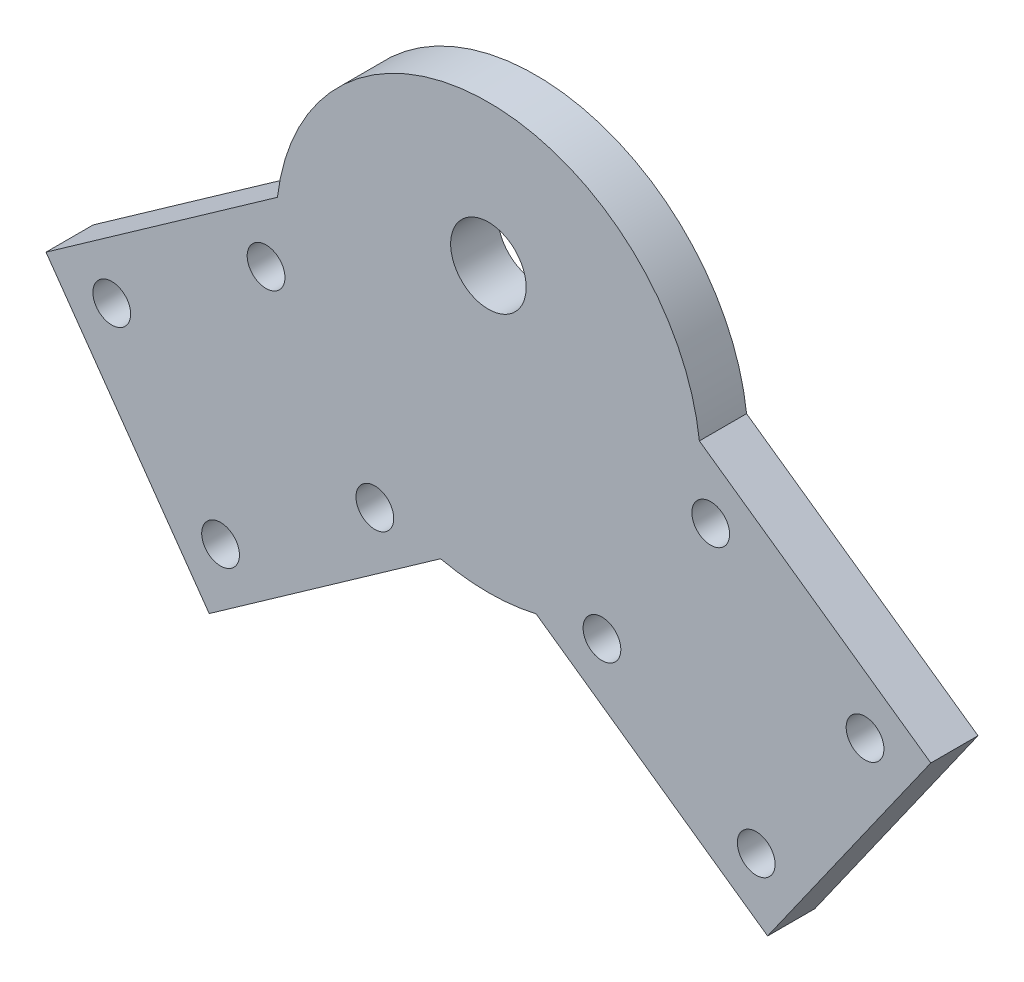
from build123d import *

# Parameters (mm, degrees)
BOSS_EXTRUDE1_DEPTH = 5
SKETCH4_R           = 2
CUT_EXTRUDE1_DEPTH  = 10
SKETCH5_R           = 4
CUT_EXTRUDE2_DEPTH  = 10


with BuildPart() as part:
    # Sketch2 → Boss-Extrude1 (new body)
    with BuildSketch(Plane.XY):
        with BuildLine():
            Line((5.061398723, -21.923326458), (29.57885851, -39.211882372))
            Line((29.57885851, -39.211882372), (46.867414424, -14.694422585))
            Line((46.867414424, -14.694422585), (22.349954637, 2.594133329))
            ThreePointArc((22.349954637, 2.594133329), (0, 22.5), (-22.349954637, 2.594133329))
            Line((-22.349954637, 2.594133329), (-46.867414424, -14.694422585))
            Line((-46.867414424, -14.694422585), (-29.57885851, -39.211882372))
            Line((-29.57885851, -39.211882372), (-5.061398723, -21.923326458))
            ThreePointArc((-5.061398723, -21.923326458), (0, -22.5), (5.061398723, -21.923326458))
        make_face()
    extrude(amount=BOSS_EXTRUDE1_DEPTH)

    # Sketch4 → Cut-Extrude1 (cut)
    with BuildSketch(Plane.XY.offset(5)):
        with Locations((-39.89974514, -15.899239897)):
            Circle(SKETCH4_R)
        with Locations((-23.554771949, -4.373535954)):
            Circle(SKETCH4_R)
        with Locations((-12.029068006, -20.718509146)):
            Circle(SKETCH4_R)
        with Locations((-28.374041198, -32.244213088)):
            Circle(SKETCH4_R)
        with Locations((23.554771949, -4.373535954)):
            Circle(SKETCH4_R)
        with Locations((12.029068006, -20.718509146)):
            Circle(SKETCH4_R)
        with Locations((39.89974514, -15.899239897)):
            Circle(SKETCH4_R)
        with Locations((28.374041198, -32.244213088)):
            Circle(SKETCH4_R)
    extrude(amount=-CUT_EXTRUDE1_DEPTH, mode=Mode.SUBTRACT)

    # Sketch5 → Cut-Extrude2 (cut)
    with BuildSketch(Plane.XY.offset(5)):
        with Locations((0, 7.5)):
            Circle(SKETCH5_R)
    extrude(amount=-CUT_EXTRUDE2_DEPTH, mode=Mode.SUBTRACT)


solid = part.part
